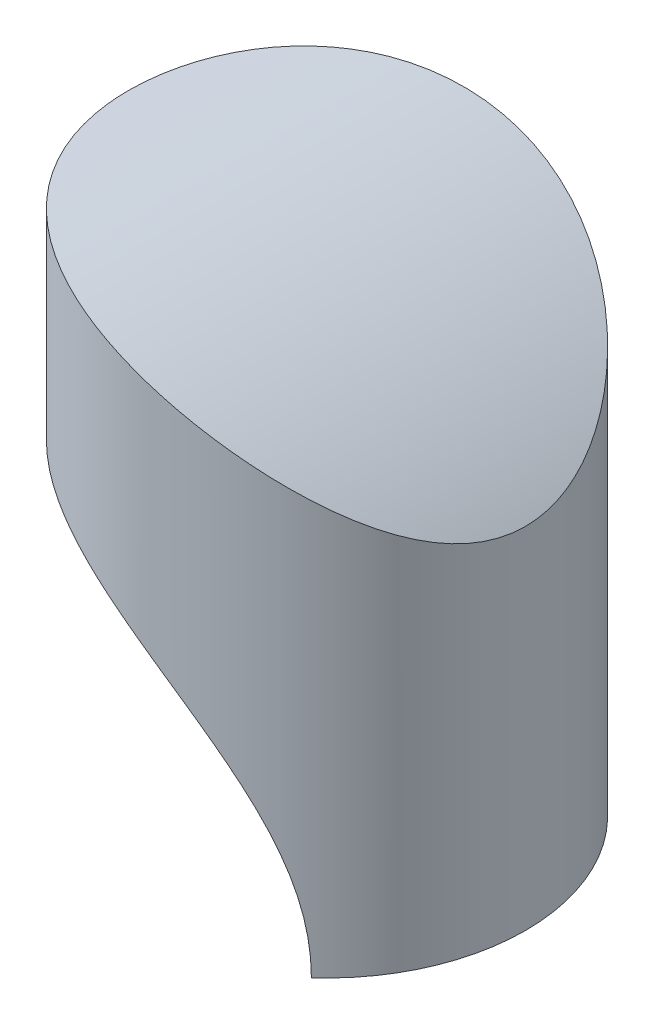
from build123d import *

# Parameters (mm, degrees)
SKETCH1_R               = 30
BOSS_EXTRUDE1_DEPTH     = 80
SKETCH2_R               = 50
CUT_EXTRUDE1_DEPTH      = 70
CUT_EXTRUDE1_DEPTH_BACK = 70
CUT_EXTRUDE2_DEPTH      = 31.0000001
CUT_EXTRUDE2_DEPTH_BACK = 31.000000109


with BuildPart() as part:
    # Sketch1 → Boss-Extrude1 (new body)
    with BuildSketch(Plane(origin=(0, 0, 0), x_dir=(1, 0, 0), z_dir=(0, 1, 0))):
        with Locations(Location((0, 0, 0), (0, 0, 270))):  # turned: the seam where the file's is
            Circle(SKETCH1_R)
    extrude(amount=BOSS_EXTRUDE1_DEPTH)

    # Sketch2 → Cut-Extrude1 (cut, two sides)
    with BuildSketch(Plane.XY) as cut_extrude1_sk:
        with Locations((-30, 0)):
            Circle(SKETCH2_R)
    extrude(amount=CUT_EXTRUDE1_DEPTH, mode=Mode.SUBTRACT)
    extrude(cut_extrude1_sk.sketch, amount=-CUT_EXTRUDE1_DEPTH_BACK, mode=Mode.SUBTRACT)

    # Sketch3 → Cut-Extrude2 (cut, two sides)
    with BuildSketch(Plane.XY) as cut_extrude2_sk:
        with BuildLine():
            Line((-30, 80), (30, 80))
            Line((30, 80), (30, 52.915026221))
            ThreePointArc((30, 52.915026221), (2.915026221, 72.915026221), (-30, 80))
        make_face()
    extrude(amount=CUT_EXTRUDE2_DEPTH, mode=Mode.SUBTRACT)
    extrude(cut_extrude2_sk.sketch, amount=-CUT_EXTRUDE2_DEPTH_BACK, mode=Mode.SUBTRACT)


solid = part.part
